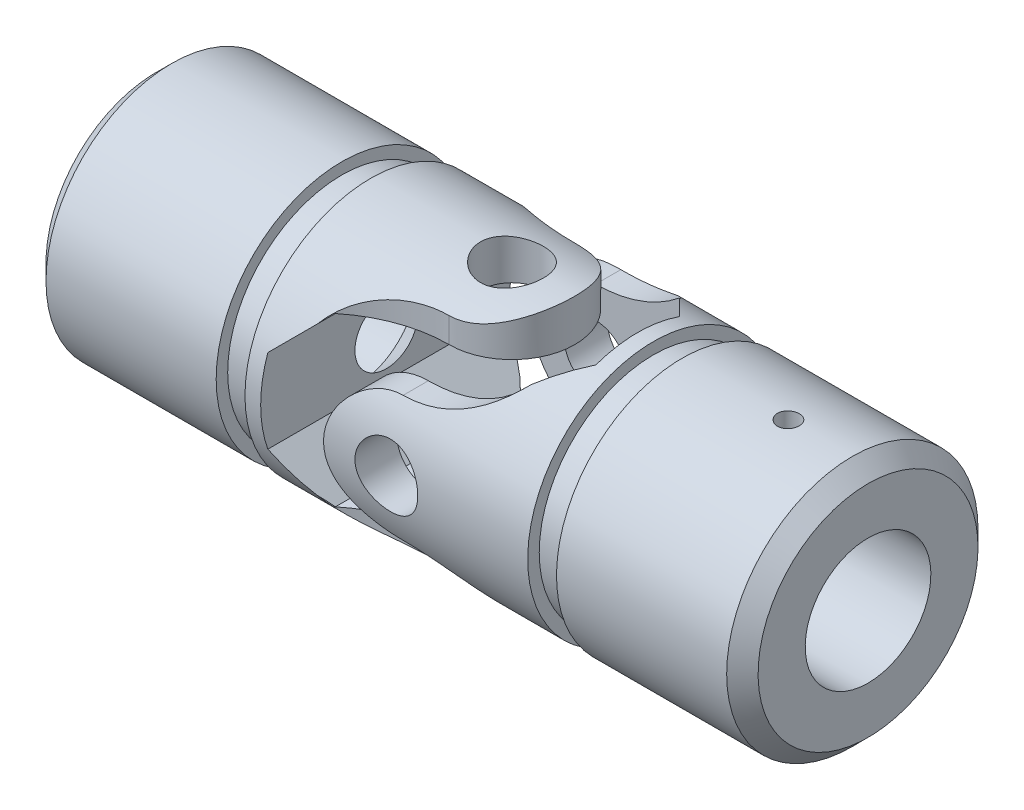
from build123d import *

# Parameters (mm, degrees)
CHAMFER1_SIZE           = 2.38125
EXTRUDE1_DEPTH          = 61.325
EXTRUDE1_DEPTH_BACK     = 61.325
EXTRUDE3_DEPTH          = 61.325000063
EXTRUDE3_DEPTH_BACK     = 61.325000063
SKETCH4_R               = 9.525
EXTRUDE4_DEPTH          = 30.1625
EXTRUDE6_DEPTH          = 61.325000063
EXTRUDE6_DEPTH_BACK     = 61.325000063
SKETCH6_R               = 4.7625
BODY_MOVE_COPY1_ANGLE   = 90
CUT_EXTRUDE1_DEPTH      = 61.325000063
CUT_EXTRUDE1_DEPTH_BACK = 61.325000063
SKETCH19_R              = 1.651


with BuildPart() as part:
    # Sketch1 → Revolve1 (revolve)
    with BuildSketch(Plane(origin=(0, 0, 0), x_dir=(1, 0, 0), z_dir=(0, 1, 0)), mode=Mode.PRIVATE) as revolve1_sk:
        Polygon((-53.975, 19.05), (-25.796875, 19.05), (-25.796875, 17.30375), (-21.43125, 17.30375), (-21.43125, 19.05), (9.525, 19.05), (9.525, 0), (-53.975, 0), align=None)
    revolve(revolve1_sk.sketch.rotate(Axis((-53.975, 0, 0), (1, 0, 0)), 180), axis=Axis((-53.975, 0, 0), (1, 0, 0)))

    # Chamfer1
    chamfer1_edges = [part.edges().sort_by_distance(p)[0] for p in [
        (-53.975, 0, -19.05),
    ]]
    chamfer(chamfer1_edges, length=CHAMFER1_SIZE)

    # Sketch2 → Extrude1 (cut, two sides: drawn at the far end of the back side and taken through both)
    with BuildSketch(Plane(origin=(0, 0, 0), x_dir=(1, 0, 0), z_dir=(0, 1, 0)).offset(-EXTRUDE1_DEPTH_BACK)):
        with BuildLine():
            Line((-17.065625, 19.05), (19.05, 19.05))
            Line((19.05, 19.05), (19.05, -19.05))
            Line((19.05, -19.05), (-17.065625, -19.05))
            ThreePointArc((-17.065625, -19.05), (-9.7719136, -12.067443862), (0, -9.525))
            ThreePointArc((0, -9.525), (9.525, 0), (0, 9.525))
            ThreePointArc((0, 9.525), (-9.7719136, 12.067443862), (-17.065625, 19.05))
        make_face()
    extrude(amount=EXTRUDE1_DEPTH + EXTRUDE1_DEPTH_BACK, mode=Mode.SUBTRACT)

    # Sketch3 → Extrude3 (cut, two sides: drawn at the far end of the back side and taken through both)
    with BuildSketch(Plane.XY.offset(-EXTRUDE3_DEPTH_BACK)):
        Polygon((-12.70635, 12.6873), (-19.05, 6.34365), (-19.05, -6.34365), (-12.70635, -12.6873), (19.05, -12.6873), (19.05, 12.6873), align=None)
    extrude(amount=EXTRUDE3_DEPTH + EXTRUDE3_DEPTH_BACK, mode=Mode.SUBTRACT)

    # Sketch4 → Extrude4 (cut)
    with BuildSketch(Plane.ZY.offset(53.975)):
        Circle(SKETCH4_R)
    extrude(amount=-EXTRUDE4_DEPTH, mode=Mode.SUBTRACT)

    # Extrude5 cone 1 section (through the dimple's axis) → Extrude5 (revolve, cut)
    with BuildSketch(Plane(origin=(-23.8125, 0, 0), x_dir=(0, 0, 1), z_dir=(0, 1, 0))):
        Polygon((0, 0), (9.525, 0), (0, 9.525), align=None)
    revolve(axis=Axis((-23.8125, 0, 0), (1, 0, 0)), mode=Mode.SUBTRACT)

    # Sketch6 → Extrude6 (cut, two sides: drawn at the far end of the back side and taken through both)
    with BuildSketch(Plane(origin=(0, 0, 0), x_dir=(1, 0, 0), z_dir=(0, 1, 0)).offset(-EXTRUDE6_DEPTH_BACK)):
        with Locations(Location((0, 0, 0), (0, 0, 270))):
            Circle(SKETCH6_R)
    extrude(amount=EXTRUDE6_DEPTH + EXTRUDE6_DEPTH_BACK, mode=Mode.SUBTRACT)


with BuildPart() as body_2:
    # Mirror1: mirrored copy
    add(part.part.mirror(Plane(origin=(0, 0, 0), x_dir=(0, 0, 1), z_dir=(1, 0, 0))))


with BuildPart() as body_2_1:
    # Body-Move/Copy1: moved
    add(body_2.part.rotate(Axis((0, 0, 0), (1, 0, 0)), BODY_MOVE_COPY1_ANGLE))

    # Sketch19 → Cut-Extrude1 (cut, two sides: drawn at the far end of the back side and taken through both)
    with BuildSketch(Plane(origin=(0, 0, 0), x_dir=(1, 0, 0), z_dir=(0, 1, 0)).offset(-CUT_EXTRUDE1_DEPTH_BACK)):
        with Locations(Location((41.91, 0, 0), (0, 0, 270))):
            Circle(SKETCH19_R)
    extrude(amount=CUT_EXTRUDE1_DEPTH + CUT_EXTRUDE1_DEPTH_BACK, mode=Mode.SUBTRACT)


solid = Compound([part.part, body_2_1.part])
